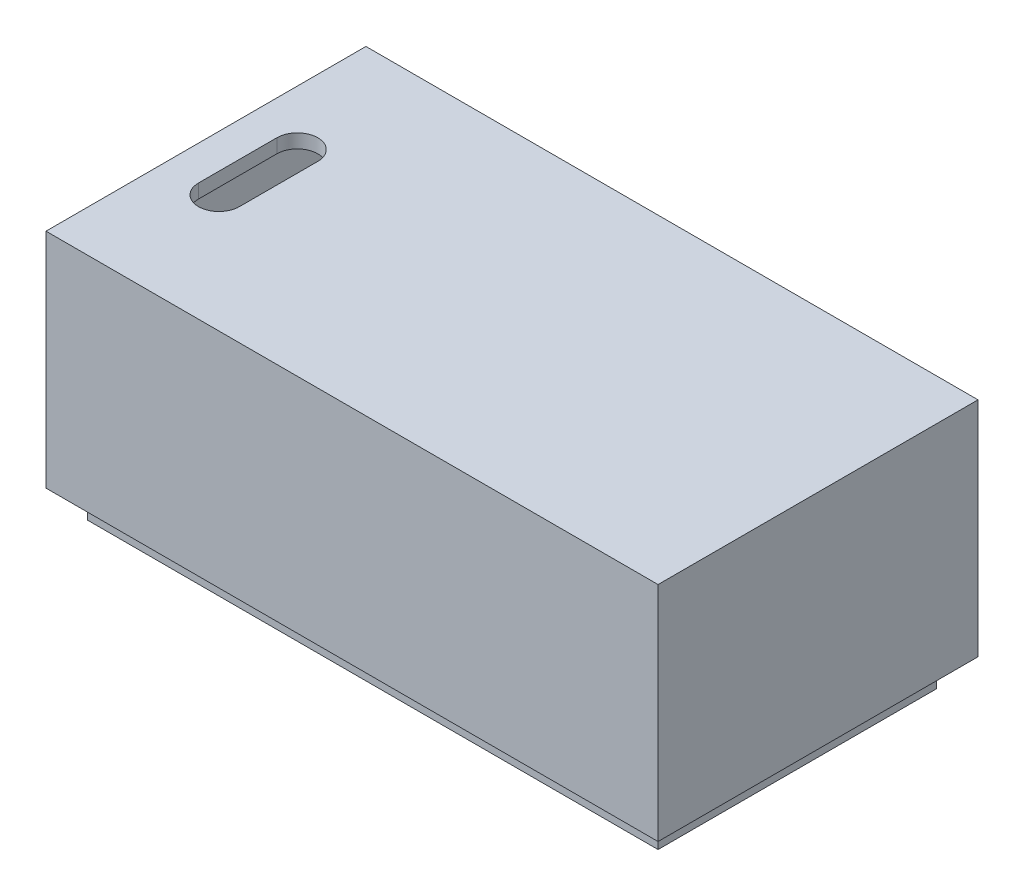
from build123d import *

# Parameters (mm, degrees)
SKETCH3_W           = 55.88
SKETCH3_H           = 29.21
BOSS_EXTRUDE4_DEPTH = 20.32
SKETCH5_W           = 53.34
SKETCH5_H           = 17.78
CUT_EXTRUDE1_DEPTH  = 27.94
CUT_EXTRUDE2_REACH  = 22.32
SKETCH7_W           = 52.07
SKETCH7_H           = 25.4
BOSS_EXTRUDE5_DEPTH = 2.54
CUT_EXTRUDE3_REACH  = 55.975
SKETCH8_W           = 23.876
SKETCH8_H           = 1.778


with BuildPart() as part:
    # Sketch3 → Boss-Extrude4 (new body)
    with BuildSketch(Plane(origin=(0, 0, 0), x_dir=(1, 0, 0), z_dir=(0, 1, 0))):
        with Locations((27.94, 14.605)):
            Rectangle(SKETCH3_W, SKETCH3_H)
    extrude(amount=BOSS_EXTRUDE4_DEPTH)

    # Sketch5 → Cut-Extrude1 (cut)
    with BuildSketch(Plane(origin=(0, 0, -29.21), x_dir=(-1, 0, 0), z_dir=(0, 0, -1))):
        with Locations((-27.94, 10.16)):
            Rectangle(SKETCH5_W, SKETCH5_H)
    extrude(amount=-CUT_EXTRUDE1_DEPTH, mode=Mode.SUBTRACT)

    # Sketch6 → Cut-Extrude2 (cut, up to next)
    with BuildSketch(Plane(origin=(0, 20.32, 0), x_dir=(1, 0, 0), z_dir=(0, 1, 0)), mode=Mode.PRIVATE) as cut_extrude2_sk1:
        with BuildLine():
            Line((6.891061211, 17.925123576), (6.891061211, 10.769129072))
            ThreePointArc((6.891061211, 10.769129072), (5.021477061, 8.899544922), (3.151892912, 10.769129072))
            Line((3.151892912, 10.769129072), (3.151892912, 17.925123576))
            ThreePointArc((3.151892912, 17.925123576), (5.021477061, 19.794707726), (6.891061211, 17.925123576))
        make_face()
    cut_extrude2_tool1 = extrude(cut_extrude2_sk1.sketch, amount=-CUT_EXTRUDE2_REACH, mode=Mode.PRIVATE) & part.part
    add(cut_extrude2_tool1.solids().sort_by_distance((5.021477, 20.32, -14.347126))[0], mode=Mode.SUBTRACT)

    # Sketch7 → Boss-Extrude5 (add)
    with BuildSketch(Plane.XZ):
        with Locations((27.94, -14.605)):
            Rectangle(SKETCH7_W, SKETCH7_H)
    extrude(amount=BOSS_EXTRUDE5_DEPTH)

    # Sketch8 → Cut-Extrude3 (cut, up to next)
    with BuildSketch(Plane.ZY.offset(-1.905), mode=Mode.PRIVATE) as cut_extrude3_sk1:
        with Locations((-14.605, -0.889)):
            Rectangle(SKETCH8_W, SKETCH8_H)
    cut_extrude3_tool1 = extrude(cut_extrude3_sk1.sketch, amount=-CUT_EXTRUDE3_REACH, mode=Mode.PRIVATE) & part.part
    add(cut_extrude3_tool1.solids().sort_by_distance((1.905, -0.889, -14.605))[0], mode=Mode.SUBTRACT)


solid = part.part
